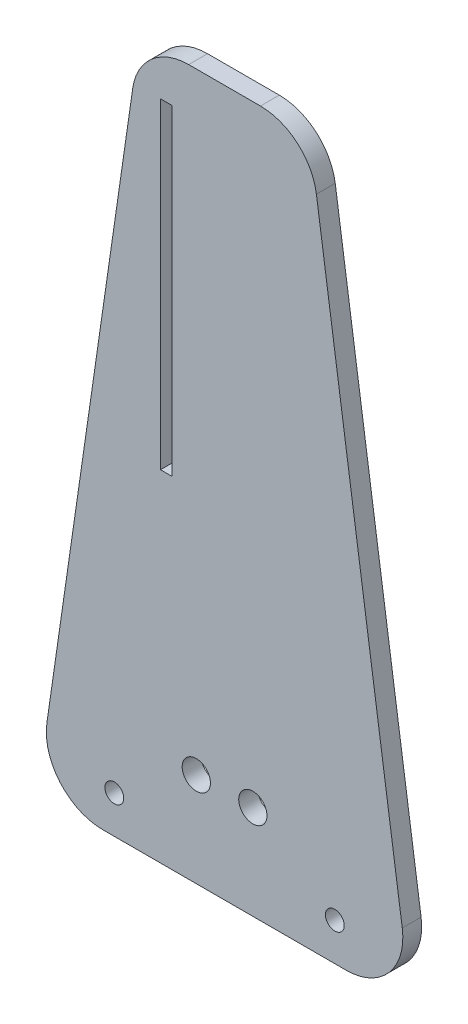
from build123d import *

# Parameters (mm, degrees)
SKETCH_1_R      = 1
SKETCH_1_R_2    = 1.5
SKETCH_1_W      = 1.2
SKETCH_1_H      = 34.088931988
EXTRUDE_1_DEPTH = 2


with BuildPart() as part:
    # 草图1 → 凸台-拉伸1 (new body)
    with BuildSketch(Plane.XY):
        with BuildLine():
            Line((-12.91723747, 0), (12.91723747, 0))
            ThreePointArc((12.91723747, 0), (17.453878353, 2.073310619), (18.855230664, 6.860370167))
            Line((18.855230664, 6.860370167), (9.744693373, 69.738315612))
            ThreePointArc((9.744693373, 69.738315612), (7.73338956, 73.414586328), (3.806700178, 74.877945445))
            Line((3.806700178, 74.877945445), (0, 74.877945445))
            Line((0, 74.877945445), (-3.806700178, 74.877945445))
            ThreePointArc((-3.806700178, 74.877945445), (-7.73338956, 73.414586328), (-9.744693373, 69.738315612))
            Line((-9.744693373, 69.738315612), (-18.855230664, 6.860370167))
            ThreePointArc((-18.855230664, 6.860370167), (-17.453878353, 2.073310619), (-12.91723747, 0))
        make_face()
        with Locations((11.7, 4)):
            Circle(SKETCH_1_R, mode=Mode.SUBTRACT)
        with Locations((-11.7, 4)):
            Circle(SKETCH_1_R, mode=Mode.SUBTRACT)
        with Locations((-3, 10)):
            Circle(SKETCH_1_R_2, mode=Mode.SUBTRACT)
        with Locations((3, 10)):
            Circle(SKETCH_1_R_2, mode=Mode.SUBTRACT)
        with Locations((-6.2, 53.192179666)):
            Rectangle(SKETCH_1_W, SKETCH_1_H, mode=Mode.SUBTRACT)
    extrude(amount=EXTRUDE_1_DEPTH)


solid = part.part
